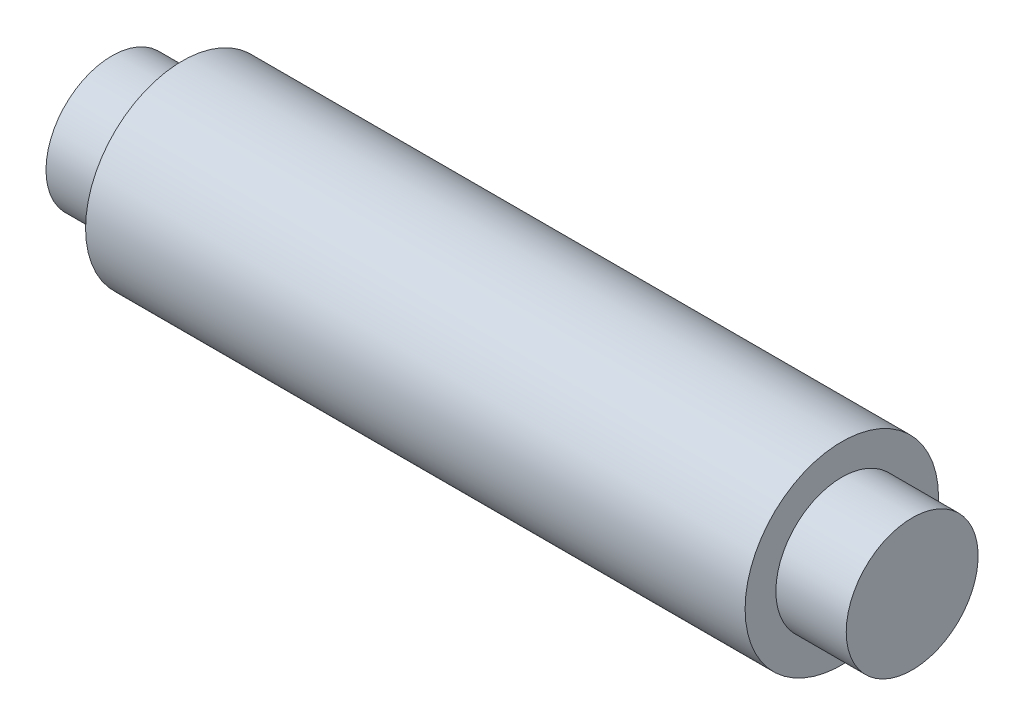
from build123d import *


with BuildPart() as part:
    # Sketch1 → Revolve1 (revolve)
    with BuildSketch(Plane.XY):
        Polygon((-45.5, 0), (-45.5, 7.5), (-37.5, 7.5), (-37.5, 11), (37.5, 11), (37.5, 7.5), (45.5, 7.5), (45.5, 0), align=None)
    revolve(axis=Axis((-45.5, 0, 0), (1, 0, 0)))


solid = part.part
